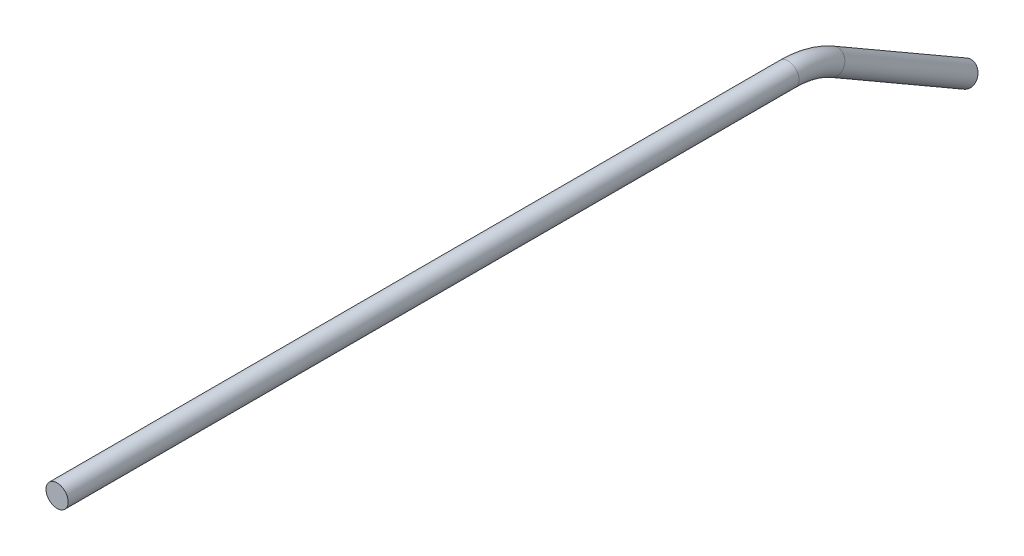
from build123d import *

# Parameters (mm, degrees)
SKETCH2_R = 3.175


with BuildPart() as part:
    # Sweep1: sweep along a path in Sketch4
    with BuildLine(Plane(origin=(0, 0, 0), x_dir=(0, 0, -1), z_dir=(1, 0, 0))) as sweep1_path:
        Line((0, 0), (209.094090512, 0))
        ThreePointArc((209.094090512, 0), (215.668094258, -0.865484012), (221.794090512, -3.402954744))
        Line((221.794090512, -3.402954744), (259.894090512, -25.4))
    # Sketch2 → Sweep1 (sweep)
    with BuildSketch(Plane.XY):
        Circle(SKETCH2_R)
    sweep(path=sweep1_path.line)


solid = part.part
